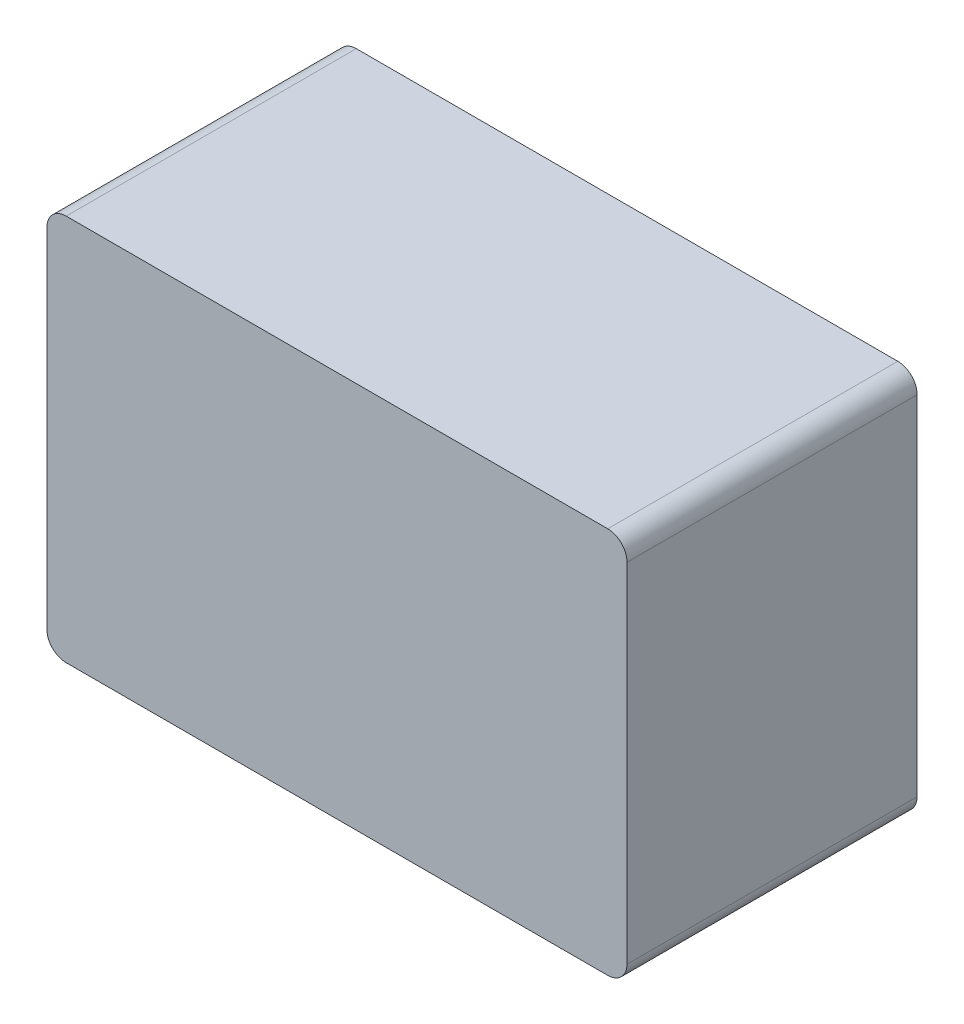
from build123d import *

# Parameters (mm, degrees)
SKETCH2_W           = 300
SKETCH2_H           = 200
BOSS_EXTRUDE1_DEPTH = 150
FILLET1_R           = 10


with BuildPart() as part:
    # Sketch2 → Boss-Extrude1 (new body)
    with BuildSketch(Plane.XY):
        with Locations((150, 100)):
            Rectangle(SKETCH2_W, SKETCH2_H)
    extrude(amount=BOSS_EXTRUDE1_DEPTH)

    # Fillet1
    fillet1_edges = [part.edges().sort_by_distance(p)[0] for p in [
        (0, 200, 75),
        (300, 200, 75),
        (300, 0, 75),
        (0, 0, 75),
    ]]
    fillet(fillet1_edges, radius=FILLET1_R)


solid = part.part
